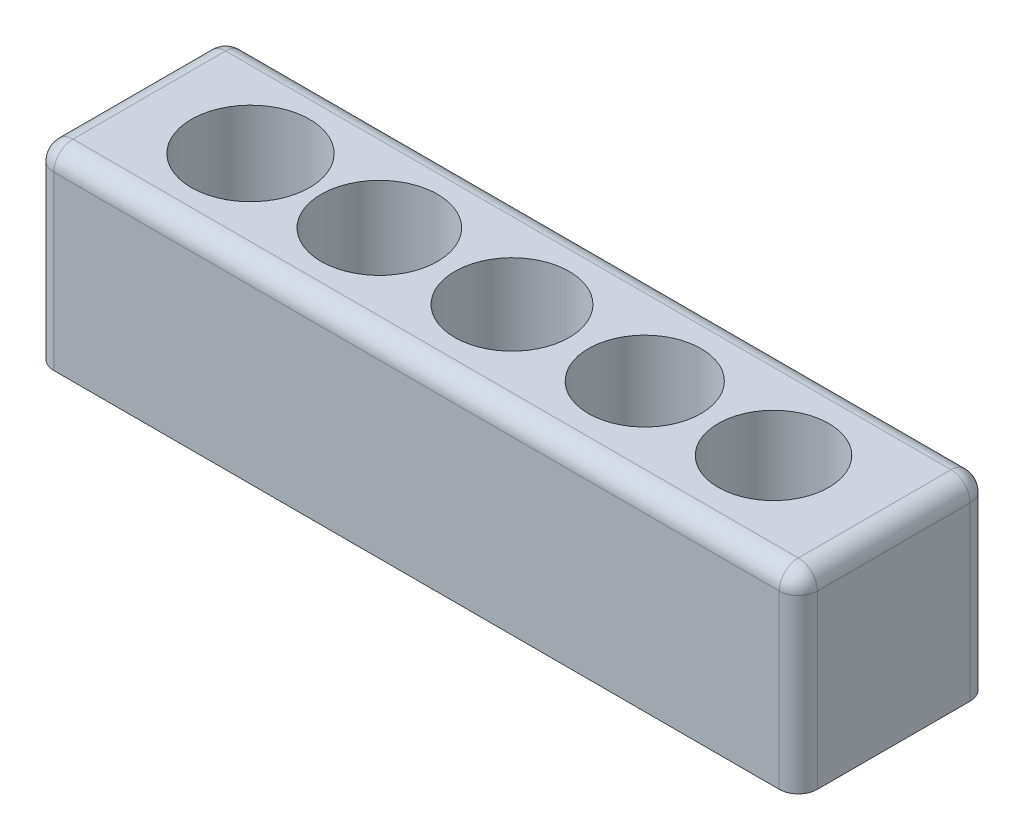
from build123d import *

# Parameters (mm, degrees)
SKETCH2_W           = 17
SKETCH2_H           = 5
BOSS_EXTRUDE1_DEPTH = 5
SKETCH3_R           = 1.5
SKETCH3_R_2         = 1.45
SKETCH3_R_3         = 1.55
SKETCH3_R_4         = 1.525
SKETCH3_R_5         = 1.475
CUT_EXTRUDE1_DEPTH  = 6
SKETCH4_W           = 5
SKETCH4_H           = 5
BOSS_EXTRUDE2_DEPTH = 1.5
SKETCH5_W           = 5
SKETCH5_H           = 5
BOSS_EXTRUDE3_DEPTH = 1.5
FILLET1_R           = 0.5


with BuildPart() as part:
    # Sketch2 → Boss-Extrude1 (new body)
    with BuildSketch(Plane(origin=(0, 0, 0), x_dir=(1, 0, 0), z_dir=(0, 1, 0))):
        with Locations((1.12006706, -0.094563726)):
            Rectangle(SKETCH2_W, SKETCH2_H)
    extrude(amount=BOSS_EXTRUDE1_DEPTH)

    # Sketch3 → Cut-Extrude1 (cut, through all)
    with BuildSketch(Plane(origin=(0, 5, 0), x_dir=(1, 0, 0), z_dir=(0, 1, 0))):
        with Locations((1.12006706, -0.094563726)):
            Circle(SKETCH3_R)
        with Locations((7.97006706, -0.094563726)):
            Circle(SKETCH3_R_2)
        with Locations((-5.72993294, -0.094563726)):
            Circle(SKETCH3_R_3)
        with Locations((-2.354549871, -0.094563726)):
            Circle(SKETCH3_R_4)
        with Locations((4.597069825, -0.094563726)):
            Circle(SKETCH3_R_5)
    extrude(amount=-CUT_EXTRUDE1_DEPTH, mode=Mode.SUBTRACT)

    # Sketch4 → Boss-Extrude2 (add)
    with BuildSketch(Plane.ZY.offset(7.37993294)):
        with Locations((0.094563726, 2.5)):
            Rectangle(SKETCH4_W, SKETCH4_H)
    extrude(amount=BOSS_EXTRUDE2_DEPTH)

    # Sketch5 → Boss-Extrude3 (add)
    with BuildSketch(Plane(origin=(9.62006706, 0, 0), x_dir=(0, 0, -1), z_dir=(1, 0, 0))):
        with Locations((-0.094563726, 2.5)):
            Rectangle(SKETCH5_W, SKETCH5_H)
    extrude(amount=BOSS_EXTRUDE3_DEPTH)

    # Fillet1
    fillet1_edges = [part.edges().sort_by_distance(p)[0] for p in [
        (1.12006706, 5, -2.405436274),
        (-8.87993294, 2.5, -2.405436274),
        (-8.87993294, 2.5, 2.594563726),
        (-8.87993294, 5, 0.094563726),
        (11.12006706, 2.5, 2.594563726),
        (11.12006706, 2.5, -2.405436274),
        (11.12006706, 5, 0.094563726),
        (1.12006706, 5, 2.594563726),
    ]]
    fillet(fillet1_edges, radius=FILLET1_R)


solid = part.part
